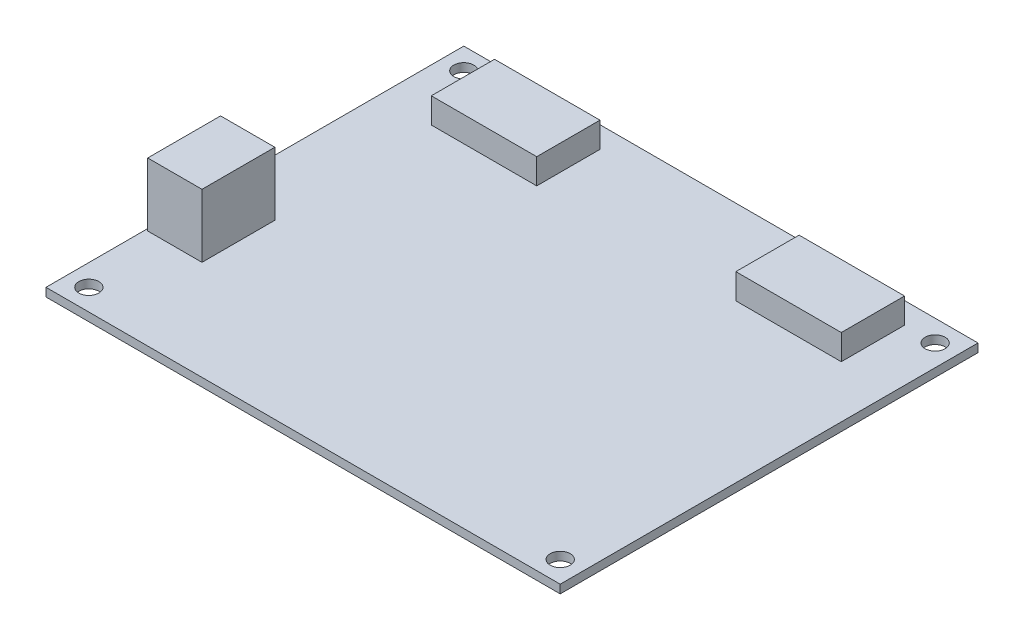
from build123d import *

# Parameters (mm, degrees)
SKETCH1_W           = 121.92
SKETCH1_H           = 99.06
BOSS_EXTRUDE1_DEPTH = 2
SKETCH2_R           = 2.371054243
CUT_EXTRUDE1_DEPTH  = 2
SKETCH3_W           = 25
SKETCH3_H           = 15
BOSS_EXTRUDE2_DEPTH = 6
SKETCH4_W           = 12.871437318
SKETCH4_H           = 17.274823769
BOSS_EXTRUDE3_DEPTH = 15


with BuildPart() as part:
    # Sketch1 → Boss-Extrude1 (new body)
    with BuildSketch(Plane(origin=(0, 0, 0), x_dir=(1, 0, 0), z_dir=(0, 1, 0))):
        Rectangle(SKETCH1_W, SKETCH1_H)
    extrude(amount=BOSS_EXTRUDE1_DEPTH)

    # Sketch2 → Cut-Extrude1 (cut)
    with BuildSketch(Plane(origin=(0, 2, 0), x_dir=(1, 0, 0), z_dir=(0, 1, 0))):
        with Locations((-55.88, 44.45)):
            Circle(SKETCH2_R)
        with Locations((55.88, 44.45)):
            Circle(SKETCH2_R)
        with Locations((55.88, -44.45)):
            Circle(SKETCH2_R)
        with Locations((-55.88, -44.45)):
            Circle(SKETCH2_R)
    extrude(amount=-CUT_EXTRUDE1_DEPTH, mode=Mode.SUBTRACT)

    # Sketch3 → Boss-Extrude2 (add)
    with BuildSketch(Plane(origin=(0, 2, 0), x_dir=(1, 0, 0), z_dir=(0, 1, 0))):
        with Locations((-36.106611978, 36.968817018)):
            Rectangle(SKETCH3_W, SKETCH3_H)
        with Locations((36.106611978, 36.968817018)):
            Rectangle(SKETCH3_W, SKETCH3_H)
    extrude(amount=BOSS_EXTRUDE2_DEPTH)

    # Sketch4 → Boss-Extrude3 (add)
    with BuildSketch(Plane(origin=(0, 2, 0), x_dir=(1, 0, 0), z_dir=(0, 1, 0))):
        with Locations((-54.026164533, -17.274823769)):
            Rectangle(SKETCH4_W, SKETCH4_H)
    extrude(amount=BOSS_EXTRUDE3_DEPTH)


solid = part.part
